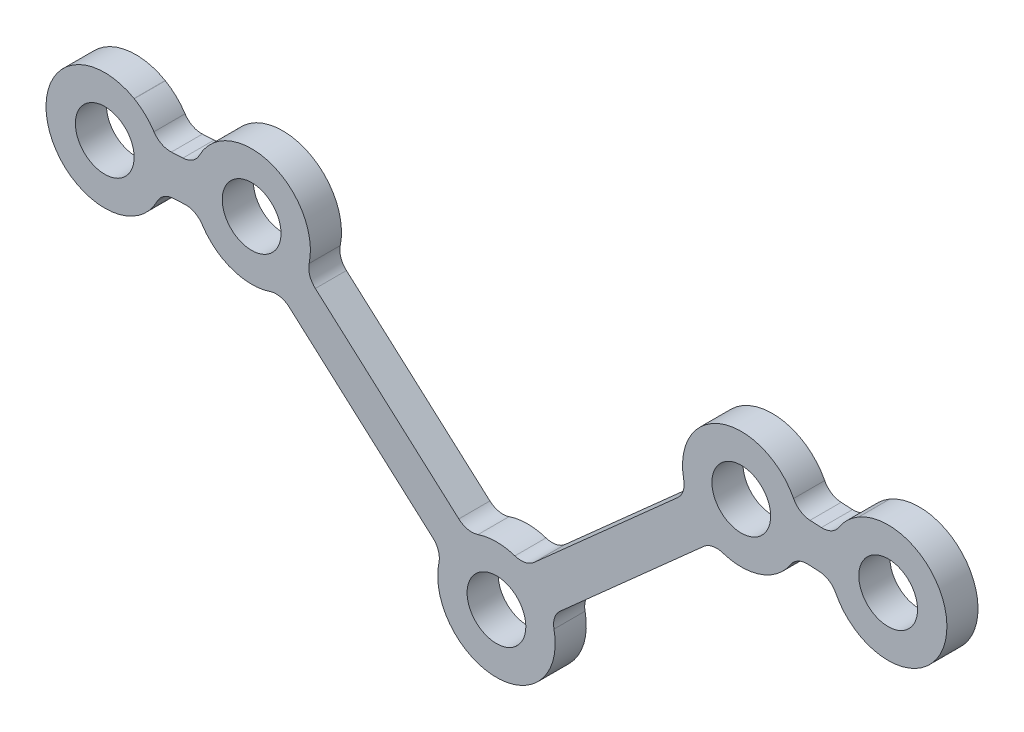
from build123d import *

# Parameters (mm, degrees)
SKETCH4_R           = 1.5
SKETCH4_R_2         = 1.500000001
SKETCH4_R_3         = 1.499999998
BOSS_EXTRUDE2_DEPTH = 1.5875


with BuildPart() as part:
    # Sketch4 → Boss-Extrude2 (new body)
    with BuildSketch(Plane.XY):
        with BuildLine():
            Line((-1.921662056, 3.050772843), (-9.248103317, 9.576404551))
            ThreePointArc((-9.248103317, 9.576404551), (-9.532363934, 10.009007248), (-9.562239502, 10.525782482))
            ThreePointArc((-9.562239502, 10.525782482), (-11.501295907, 13.962584592), (-15.168282223, 12.504928996))
            ThreePointArc((-15.168282223, 12.504928996), (-15.515981129, 12.121451925), (-16.008835749, 11.963200494))
            Line((-16.008835749, 11.963200494), (-16.599403965, 11.934302598))
            ThreePointArc((-16.599403965, 11.934302598), (-17.103207742, 12.042580302), (-17.486208385, 12.387330667))
            ThreePointArc((-17.486208385, 12.387330667), (-22.995673813, 10.588945924), (-17.32515244, 9.391622098))
            ThreePointArc((-17.32515244, 9.391622098), (-16.977285242, 9.77807758), (-16.482410468, 9.937634422))
            Line((-16.482410468, 9.937634422), (-15.911087986, 9.965590578))
            ThreePointArc((-15.911087986, 9.965590578), (-15.405137648, 9.856213028), (-15.021660578, 9.508514122))
            ThreePointArc((-15.021660578, 9.508514122), (-13.498704093, 8.304814666), (-11.557591443, 8.285565834))
            ThreePointArc((-11.557591443, 8.285565834), (-11.040816209, 8.315441402), (-10.578337944, 8.082926785))
            Line((-10.578337944, 8.082926785), (-3.251896683, 1.557295078))
            ThreePointArc((-3.251896683, 1.557295078), (-2.967636066, 1.124692381), (-2.937760498, 0.607917146))
            ThreePointArc((-2.937760498, 0.607917146), (0, -3), (2.937760498, 0.607917146))
            ThreePointArc((2.937760498, 0.607917146), (2.967636066, 1.124692381), (3.251896683, 1.557295078))
            Line((3.251896683, 1.557295078), (10.578337944, 8.082926785))
            ThreePointArc((10.578337944, 8.082926785), (11.040816209, 8.315441402), (11.557591443, 8.285565834))
            ThreePointArc((11.557591443, 8.285565834), (13.495560549, 8.303706839), (15.01804315, 9.502914943))
            ThreePointArc((15.01804315, 9.502914943), (15.40229187, 9.849760895), (15.908483998, 9.958013941))
            Line((15.908483998, 9.958013941), (16.48932974, 9.928297901))
            ThreePointArc((16.48932974, 9.928297901), (16.981831505, 9.768951725), (17.328677456, 9.384703006))
            ThreePointArc((17.328677456, 9.384703006), (22.996081677, 10.596720608), (17.481956847, 12.380784685))
            ThreePointArc((17.481956847, 12.380784685), (17.097708128, 12.033938733), (16.591516, 11.925685687))
            Line((16.591516, 11.925685687), (16.010670258, 11.955401727))
            ThreePointArc((16.010670258, 11.955401727), (15.518168493, 12.114747903), (15.171322541, 12.498996622))
            ThreePointArc((15.171322541, 12.498996622), (11.504439451, 13.963692419), (9.562239502, 10.525782482))
            ThreePointArc((9.562239502, 10.525782482), (9.532363934, 10.009007248), (9.248103317, 9.576404551))
            Line((9.248103317, 9.576404551), (1.921662056, 3.050772843))
            ThreePointArc((1.921662056, 3.050772843), (1.459183791, 2.818258227), (0.942408557, 2.848133795))
            ThreePointArc((0.942408557, 2.848133795), (0, 3), (-0.942408557, 2.848133795))
            ThreePointArc((-0.942408557, 2.848133795), (-1.459183791, 2.818258227), (-1.921662056, 3.050772843))
        make_face()
        with Locations((-12.5, 11.133699629)):
            Circle(SKETCH4_R, mode=Mode.SUBTRACT)
        with Locations((-20.000000001, 10.750000001)):
            Circle(SKETCH4_R_2, mode=Mode.SUBTRACT)
        Circle(SKETCH4_R, mode=Mode.SUBTRACT)
        with Locations((12.5, 11.133699629)):
            Circle(SKETCH4_R, mode=Mode.SUBTRACT)
        with Locations((19.999999998, 10.749999999)):
            Circle(SKETCH4_R_3, mode=Mode.SUBTRACT)
    extrude(amount=BOSS_EXTRUDE2_DEPTH)


solid = part.part
